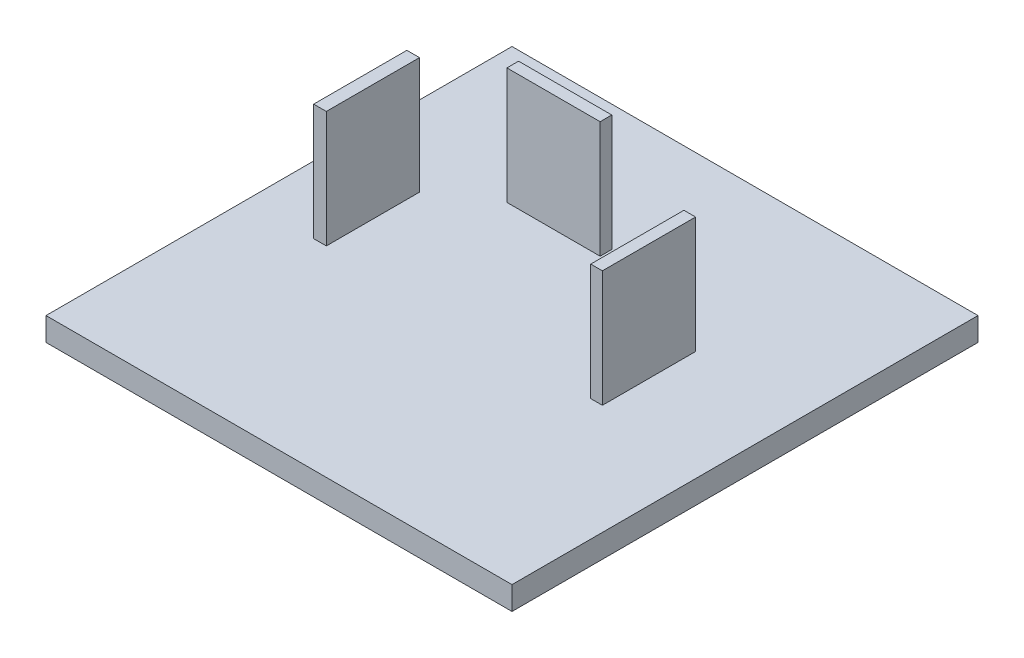
from build123d import *

# Parameters (mm, degrees)
SKETCH1_W           = 50.8
SKETCH1_H           = 2.54
BOSS_EXTRUDE1_DEPTH = 50.8
SKETCH2_W           = 10.16
SKETCH2_H           = 1.27
SKETCH2_W_2         = 1.27
SKETCH2_H_2         = 10.16
SKETCH2_W_3         = 1.379502468
BOSS_EXTRUDE2_DEPTH = 12.7


with BuildPart() as part:
    # Sketch1 → Boss-Extrude1 (new body)
    with BuildSketch(Plane.XY):
        with Locations((-118.555926356, -26.291516762)):
            Rectangle(SKETCH1_W, SKETCH1_H)
    extrude(amount=BOSS_EXTRUDE1_DEPTH)

    # Sketch2 → Boss-Extrude2 (add)
    with BuildSketch(Plane(origin=(0, -25.021516762, 0), x_dir=(1, 0, 0), z_dir=(0, 1, 0))):
        with Locations((-124.433948154, -14.360513522)):
            Rectangle(SKETCH2_W, SKETCH2_H)
        with Locations((-105.788523286, -23.868729288)):
            Rectangle(SKETCH2_W_2, SKETCH2_H_2)
        with Locations((-135.937615572, -23.868729288)):
            Rectangle(SKETCH2_W_3, SKETCH2_H_2)
    extrude(amount=BOSS_EXTRUDE2_DEPTH)


solid = part.part
